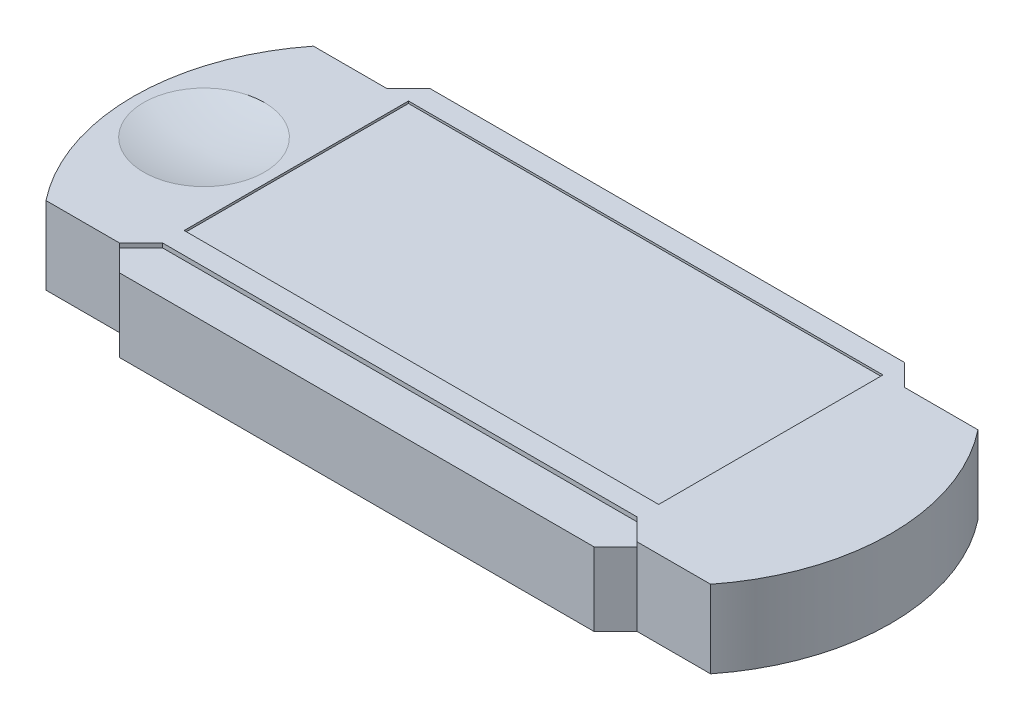
from build123d import *

# Parameters (mm, degrees)
BOSS_EXTRUDE1_DEPTH = 18
CUT_EXTRUDE1_DEPTH  = 1
SKETCH3_W           = 110
SKETCH3_H           = 52
CUT_EXTRUDE2_DEPTH  = 0.5


with BuildPart() as part:
    # Sketch1 → Boss-Extrude1 (new body)
    with BuildSketch(Plane(origin=(0, 0, 0), x_dir=(1, 0, 0), z_dir=(0, 1, 0))):
        with BuildLine():
            Line((-55, -36), (55, -36))
            Line((55, -36), (60, -31))
            Line((60, -31), (77.030090492, -31))
            ThreePointArc((77.030090492, -31), (87.8, 0), (77.030090492, 31))
            Line((77.030090492, 31), (60, 31))
            Line((60, 31), (55, 36))
            Line((55, 36), (-55, 36))
            Line((-55, 36), (-60, 31))
            Line((-60, 31), (-77.030090492, 31))
            ThreePointArc((-77.030090492, 31), (-87.8, 0), (-77.030090492, -31))
            Line((-77.030090492, -31), (-60, -31))
            Line((-60, -31), (-55, -36))
        make_face()
    extrude(amount=-BOSS_EXTRUDE1_DEPTH)

    # Sketch2 → Cut-Extrude1 (cut)
    with BuildSketch(Plane(origin=(0, 0, 0), x_dir=(1, 0, 0), z_dir=(0, 1, 0))):
        Polygon((55, -36), (60, -31), (55, -26), (-55, -26), (-60, -31), (-55, -36), align=None)
    extrude(amount=-CUT_EXTRUDE1_DEPTH, mode=Mode.SUBTRACT)

    # Sketch3 → Cut-Extrude2 (cut)
    with BuildSketch(Plane(origin=(0, 0, 0), x_dir=(1, 0, 0), z_dir=(0, 1, 0))):
        with Locations((0, 5)):
            Rectangle(SKETCH3_W, SKETCH3_H)
    extrude(amount=-CUT_EXTRUDE2_DEPTH, mode=Mode.SUBTRACT)

    # Sketch4 → Cut-Revolve1 (revolve, cut)
    with BuildSketch(Plane.XY):
        with BuildLine():
            Line((-71.4, 0), (-85.4, 0))
            ThreePointArc((-85.4, 0), (-78.464550283, -1.451851979), (-71.4, -2))
            Line((-71.4, -2), (-71.4, 0))
        make_face()
    revolve(axis=Axis((-71.4, -2, 0), (0, 1, 0)), mode=Mode.SUBTRACT)


solid = part.part
